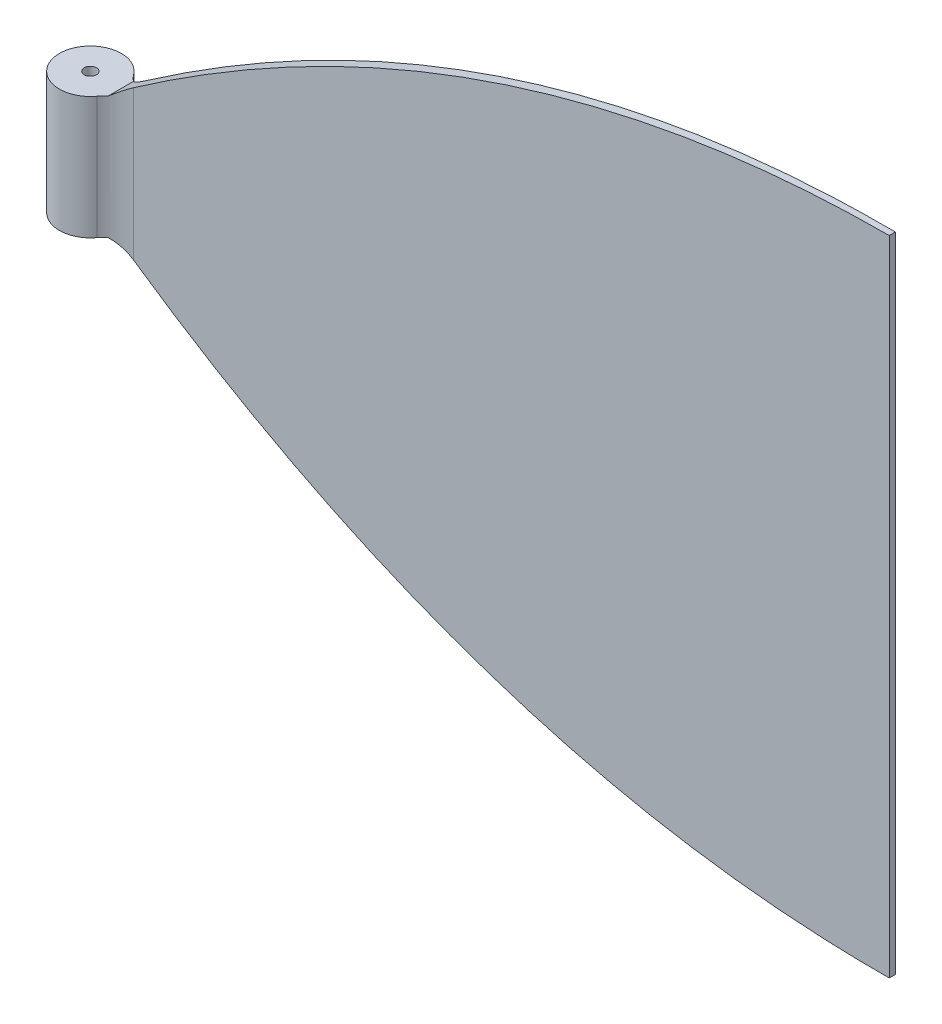
from build123d import *

# Parameters (mm, degrees)
EXTRUDE_1_DEPTH          = 2
EXTRUDE_1_DEPTH_BACK     = 2
CUT_EXTRUDE_1_DEPTH      = 106.001210011
CUT_EXTRUDE_1_DEPTH_BACK = 106.001210011
EXTRUDE_2_DEPTH          = 20
EXTRUDE_2_DEPTH_BACK     = 20
FILLET_1_R               = 10
SKETCH_5_R               = 2
CUT_EXTRUDE_2_DEPTH      = 40


with BuildPart() as part:
    # Sketch 1 → Extrude 1 (new body, two sides)
    with BuildSketch(Plane.XY) as extrude_1_sk:
        with BuildLine():
            Line((272, -105), (272, 105))
            add(Edge.make_bspline(
                [(20, 20), (138.91931348, 105.321902733), (272, 105)],
                knots=[0, 0, 0, 1, 1, 1], degree=2))
            Line((20, 20), (20, -20))
            add(Edge.make_bspline(
                [(20, -20), (138.91931348, -105.321902733), (272, -105)],
                knots=[0, 0, 0, 1, 1, 1], degree=2))
        make_face()
    extrude(amount=EXTRUDE_1_DEPTH)
    extrude(extrude_1_sk.sketch, amount=-EXTRUDE_1_DEPTH_BACK)

    # Sketch 2 → Cut-Extrude 1 (cut, two sides)
    with BuildSketch(Plane(origin=(0, 0, 0), x_dir=(1, 0, 0), z_dir=(0, 1, 0))) as cut_extrude_1_sk:
        Polygon((20, -2), (272, -1), (272, -2), align=None)
        Polygon((272, 1), (20, 2), (272, 2), align=None)
    extrude(amount=CUT_EXTRUDE_1_DEPTH, mode=Mode.SUBTRACT)
    extrude(cut_extrude_1_sk.sketch, amount=-CUT_EXTRUDE_1_DEPTH_BACK, mode=Mode.SUBTRACT)

    # Sketch 4 → Extrude 2 (add, two sides)
    with BuildSketch(Plane(origin=(0, 0, 0), x_dir=(1, 0, 0), z_dir=(0, 1, 0))) as extrude_2_sk:
        with BuildLine():
            Line((20, 2), (20, -2))
            ThreePointArc((20, -2), (0, 0), (20, 2))
        make_face()
    extrude(amount=EXTRUDE_2_DEPTH)
    extrude(extrude_2_sk.sketch, amount=-EXTRUDE_2_DEPTH_BACK)

    # Fillet 1
    fillet_1_edges = [part.edges().sort_by_distance(p)[0] for p in [
        (20, 0, -2),
        (20, 0, 2),
    ]]
    fillet(fillet_1_edges, radius=FILLET_1_R)

    # Sketch 5 → Cut-Extrude 2 (cut)
    with BuildSketch(Plane(origin=(0, 20, 0), x_dir=(1, 0, 0), z_dir=(0, 1, 0))):
        with Locations((10.1, 0)):
            Circle(SKETCH_5_R)
    extrude(amount=-CUT_EXTRUDE_2_DEPTH, mode=Mode.SUBTRACT)


solid = part.part
